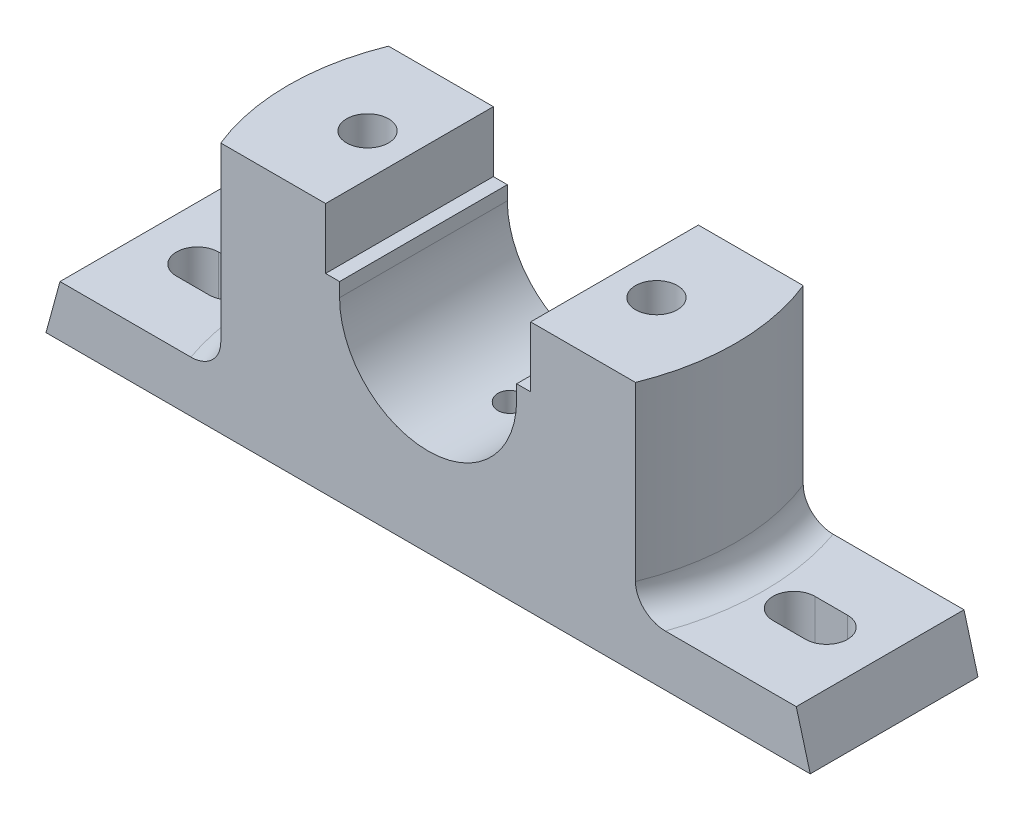
from build123d import *

# Parameters (mm, degrees)
BOSS_EXTRUDE1_DEPTH        = 18
CUT_EXTRUDE4_DEPTH         = 43
CUT_EXTRUDE5_DEPTH         = 95.323910012
SKETCH13_W                 = 20
SKETCH13_H                 = 20
CUT_EXTRUDE7_DEPTH         = 8
SKETCH18_W                 = 4.5
SKETCH18_H                 = 46
F_10_0MM_DOWEL_HOLE7_D     = 6
F_10_0MM_DOWEL_HOLE7_DEPTH = 6
F_10_0MM_DOWEL_HOLE7_TIP   = 1.802581857
CUT_EXTRUDE8_DEPTH         = 43
FILLET2_R                  = 6


with BuildPart() as part:
    # Sketch1 → Boss-Extrude1 (new, symmetric)
    with BuildSketch(Plane.XY):
        with BuildLine():
            Line((-82, 0), (82, 0))
            Line((82, 0), (79, 11))
            Line((79, 11), (50, 11))
            Line((50, 11), (50, 54))
            Line((50, 54), (22, 54))
            Line((22, 54), (22, 41))
            Line((22, 41), (19, 41))
            Line((19, 41), (19, 38))
            ThreePointArc((19, 38), (0, 19), (-19, 38))
            Line((-19, 38), (-19, 41))
            Line((-19, 41), (-22, 41))
            Line((-22, 41), (-22, 54))
            Line((-22, 54), (-50, 54))
            Line((-50, 54), (-50, 11))
            Line((-50, 11), (-79, 11))
            Line((-79, 11), (-82, 0))
        make_face()
    extrude(amount=BOSS_EXTRUDE1_DEPTH, both=True)

    # Sketch5 → Cut-Extrude4 (cut)
    with BuildSketch(Plane(origin=(0, 54, 0), x_dir=(1, 0, 0), z_dir=(0, 1, 0))):
        with BuildLine():
            Line((-44.319422925, 18.433359747), (-50, 18))
            Line((-50, 18), (-50, -18))
            Line((-50, -18), (-44.319422925, -18.433359747))
            ThreePointArc((-44.319422925, -18.433359747), (-48, 0), (-44.319422925, 18.433359747))
        make_face()
    extrude(amount=-CUT_EXTRUDE4_DEPTH, mode=Mode.SUBTRACT)

    # Sketch6 → Cut-Extrude5 (cut, through all)
    with BuildSketch(Plane(origin=(0, 11, 0), x_dir=(1, 0, 0), z_dir=(0, 1, 0))):
        with BuildLine():
            Line((-67.5, 4.5), (-60.5, 4.5))
            ThreePointArc((-60.5, 4.5), (-56, 0), (-60.5, -4.5))
            Line((-60.5, -4.5), (-67.5, -4.5))
            ThreePointArc((-67.5, -4.5), (-72, 0), (-67.5, 4.5))
        make_face()
    cut_extrude5 = extrude(amount=-CUT_EXTRUDE5_DEPTH, mode=Mode.SUBTRACT)

    # Sketch13 → Cut-Extrude7 (cut)
    with BuildSketch(Plane.XZ):
        with Locations((-31, 1.039658797)):
            Rectangle(SKETCH13_W, SKETCH13_H)
    cut_extrude7 = extrude(amount=-CUT_EXTRUDE7_DEPTH, mode=Mode.SUBTRACT)

    # Sketch18 → Ø10.0mm Dowel Hole5 (revolve, cut)
    with BuildSketch(Plane(origin=(-31, 8, 0), x_dir=(0, 0, -1), z_dir=(1, 0, 0))):
        with Locations((2.25, 23)):
            Rectangle(SKETCH18_W, SKETCH18_H)
    f_10_0mm_dowel_hole5 = revolve(axis=Axis((-31, 1.65, 0), (0, 1, 0)), mode=Mode.SUBTRACT)

    # Mirror3: Cut-Extrude5, Ø10.0mm Dowel Hole5 across plane
    add(cut_extrude5.mirror(Plane(origin=(0, 0, 0), x_dir=(0, 0, 1), z_dir=(1, 0, 0))), mode=Mode.SUBTRACT)
    add(f_10_0mm_dowel_hole5.mirror(Plane(origin=(0, 0, 0), x_dir=(0, 0, 1), z_dir=(1, 0, 0))), mode=Mode.SUBTRACT)

    # Ø10.0mm Dowel Hole7
    with Locations(Plane(origin=(0, 19, 0), x_dir=(1, 0, 0), z_dir=(0, 1, 0))):
        with Locations((0, 0)):
            Hole(F_10_0MM_DOWEL_HOLE7_D / 2, depth=F_10_0MM_DOWEL_HOLE7_DEPTH)
            with Locations((0, 0, -(F_10_0MM_DOWEL_HOLE7_DEPTH + F_10_0MM_DOWEL_HOLE7_TIP / 2))):  # 118° drill point
                Cone(0, F_10_0MM_DOWEL_HOLE7_D / 2, F_10_0MM_DOWEL_HOLE7_TIP, mode=Mode.SUBTRACT)

    # Sketch25 → Cut-Extrude8 (cut)
    with BuildSketch(Plane(origin=(0, 54, 0), x_dir=(1, 0, 0), z_dir=(0, 1, 0))):
        with BuildLine():
            Line((44.497190923, 18), (50, 18))
            Line((50, 18), (50, -18))
            Line((50, -18), (44.497190923, -18))
            ThreePointArc((44.497190923, -18), (48, 0), (44.497190923, 18))
        make_face()
    extrude(amount=-CUT_EXTRUDE8_DEPTH, mode=Mode.SUBTRACT)

    # Fillet2
    fillet2_edges = [part.edges().sort_by_distance(p)[0] for p in [
        (48, 11, 0),
        (-48, 11, 0),
    ]]
    fillet(fillet2_edges, radius=FILLET2_R)

    # Mirror4: Cut-Extrude7 across plane
    add(cut_extrude7.mirror(Plane(origin=(0, 0, 0), x_dir=(0, 0, 1), z_dir=(1, 0, 0))), mode=Mode.SUBTRACT)


solid = part.part
